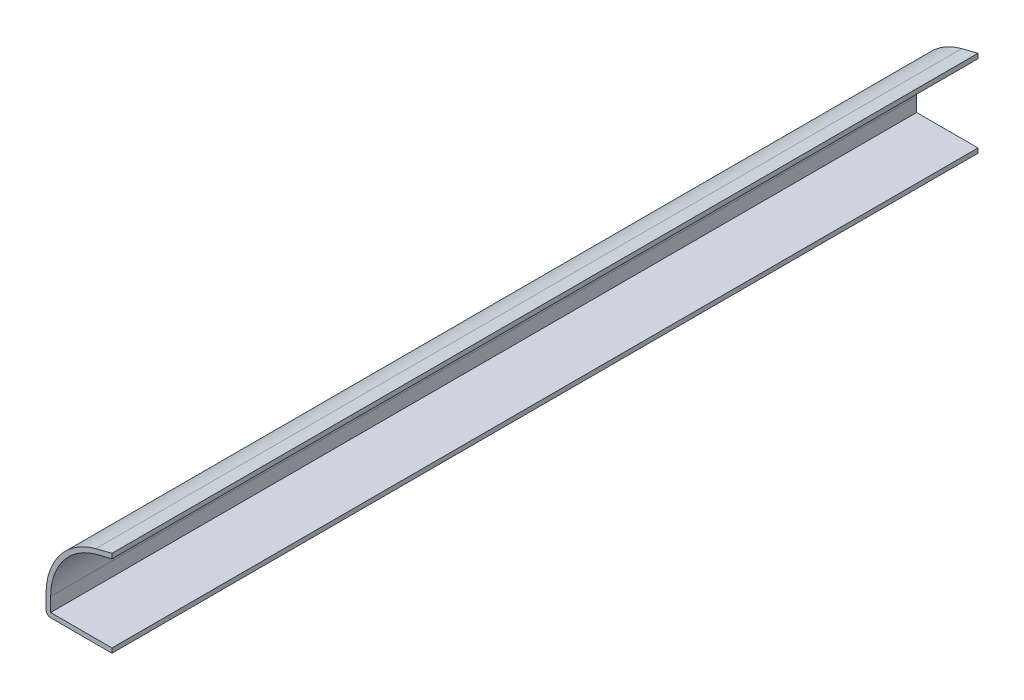
from build123d import *

# Parameters (mm, degrees)
EXTRUDE_THIN1_DEPTH     = 166.6875
FILLET1_R               = 0.889
CUT_EXTRUDE1_DEPTH      = 1
CUT_EXTRUDE1_DEPTH_BACK = 167.6875


with BuildPart() as part:
    # Sketch1 → Extrude-Thin1 (new body)
    with BuildSketch(Plane.XY):
        with BuildLine():
            Line((0, 16.66875), (-3.125784133, 15.875))
            ThreePointArc((-3.125784133, 15.875), (-10.024656066, 11.362871681), (-12.7, 3.565675341))
            Line((-12.7, 3.565675341), (-12.7, 0))
            Line((-12.7, 0), (0, 0))
            Line((0, 0), (0, 0.889))
            Line((0, 0.889), (-11.811, 0.889))
            Line((-11.811, 0.889), (-11.811, 3.565675341))
            ThreePointArc((-11.811, 3.565675341), (-9.322930142, 10.817067937), (-2.906979244, 15.013347274))
            Line((-2.906979244, 15.013347274), (0.218804889, 15.807097274))
            Line((0.218804889, 15.807097274), (0, 16.66875))
        make_face()
    extrude(amount=-EXTRUDE_THIN1_DEPTH)

    # Fillet1
    fillet1_edges = [part.edges().sort_by_distance(p)[0] for p in [
        (-12.7, 0, -83.34375),
    ]]
    fillet(fillet1_edges, radius=FILLET1_R)

    # Sketch2 → Cut-Extrude1 (cut, two sides)
    with BuildSketch(Plane.XY) as cut_extrude1_sk:
        Polygon((0, -55.634586178), (0, 0.889), (0, 19.48899735), (0, 76.012583528), (113.047172356, 76.012583528), (113.047172356, -55.634586178), align=None)
    extrude(amount=CUT_EXTRUDE1_DEPTH, mode=Mode.SUBTRACT)
    extrude(cut_extrude1_sk.sketch, amount=-CUT_EXTRUDE1_DEPTH_BACK, mode=Mode.SUBTRACT)


solid = part.part
